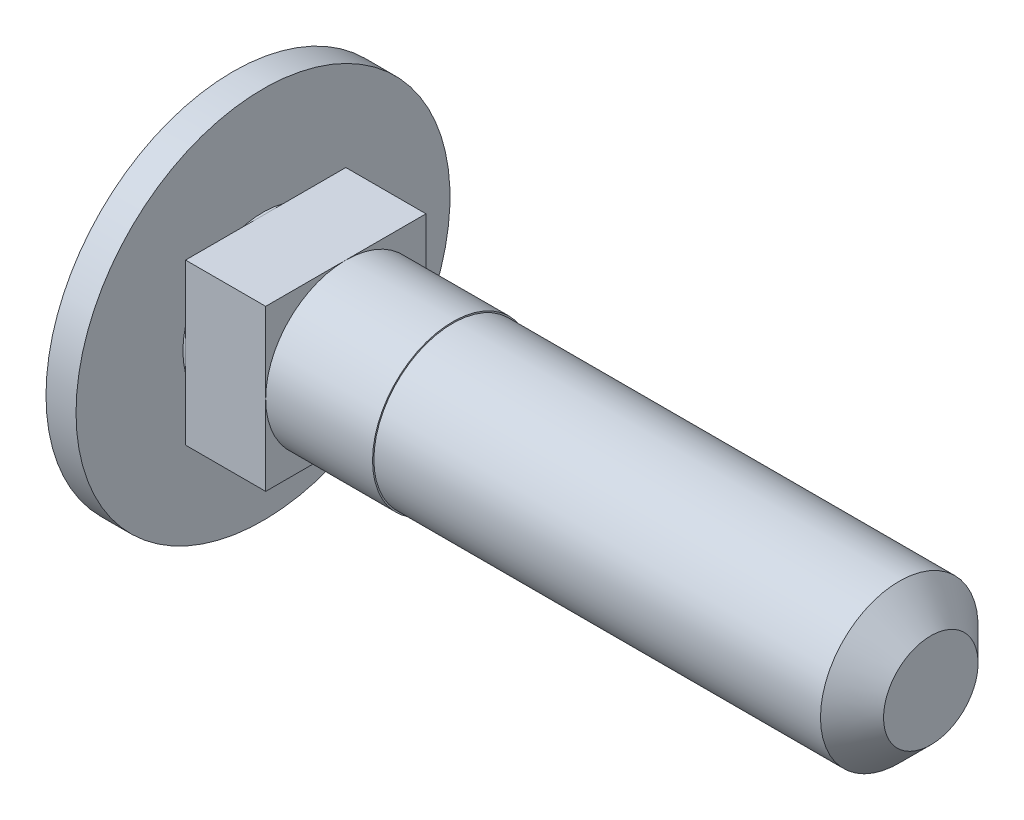
from build123d import *

# Parameters (mm, degrees)
EXTRUDE_START   = 0.1
SKETCH_2_W      = 6
SKETCH_2_H      = 6
EXTRUDE_1_DEPTH = 3
CHAMFER_1_SIZE  = 1.18


with BuildPart() as part:
    # Эскиз1 → Повернуть1 (revolve)
    with BuildSketch(Plane.XY, mode=Mode.PRIVATE) as revolve_1_sk:
        with BuildLine():
            Line((25, 0), (25, 2.95))
            Line((25, 2.95), (7.1, 2.95))
            Line((7.1, 2.95), (7.1, 3))
            Line((7.1, 3), (0, 3))
            Line((0, 3), (0, 7))
            Line((0, 7), (-1.124355653, 7))
            ThreePointArc((-1.124355653, 7), (-2.522961568, 3.623466631), (-3, 0))
            Line((-3, 0), (25, 0))
        make_face()
    revolve(revolve_1_sk.sketch.rotate(Axis((-121.430503085, 0, 0), (1, 0, 0)), 90), axis=Axis((-121.430503085, 0, 0), (1, 0, 0)))

    # Эскиз2 → Бобышка-Вытянуть1 (add)
    with BuildSketch(Plane(origin=(0, 0, 0), x_dir=(0, 0, -1), z_dir=(1, 0, 0)).offset(EXTRUDE_START)):
        Rectangle(SKETCH_2_W, SKETCH_2_H)
    extrude(amount=EXTRUDE_1_DEPTH)

    # Фаска1
    chamfer_1_edges = [part.edges().sort_by_distance(p)[0] for p in [
        (25, 0, -2.95),
    ]]
    chamfer(chamfer_1_edges, length=CHAMFER_1_SIZE)


solid = part.part
